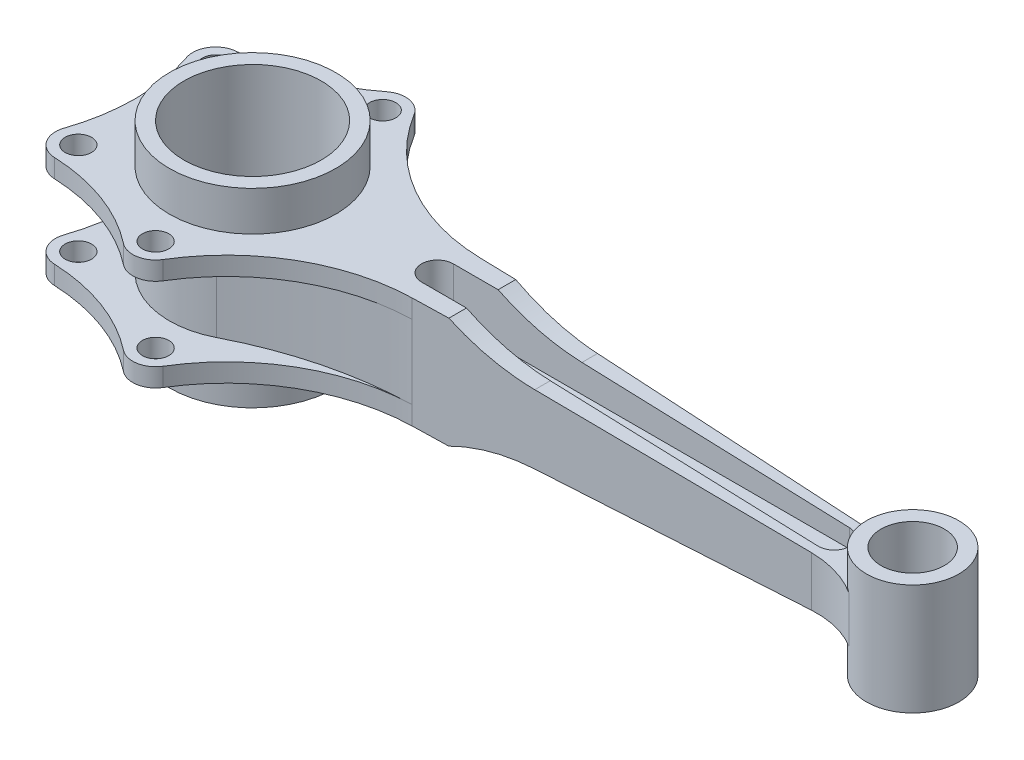
from build123d import *

# Parameters (mm, degrees)
SKETCH1_R                           = 31.5
SKETCH1_R_2                         = 26
BOSS_EXTRUDE4_DEPTH                 = 36
SKETCH1_6_R                         = 31.5
BOSS_EXTRUDE5_DEPTH                 = 21
SKETCH1_7_R                         = 17.499999999999996
SKETCH1_7_R_2                       = 12.000000000000032
BOSS_EXTRUDE6_DEPTH                 = 21
CUT_EXTRUDE2_DEPTH                  = 14
F_10_0_10_DIAMETER_HOLE1_AT_2_COUNT = 2
F_10_0_10_DIAMETER_HOLE1_AT_2_PITCH = 49.29432288112943
F_10_0_10_DIAMETER_HOLE1_AT_3_COUNT = 2
F_10_0_10_DIAMETER_HOLE1_AT_3_PITCH = 83.07785666655731
F_10_0_10_DIAMETER_HOLE1_AT_4_COUNT = 2
F_10_0_10_DIAMETER_HOLE1_AT_4_PITCH = 86
CUT_EXTRUDE3_DEPTH                  = 275.8107850129084
CUT_EXTRUDE5_START                  = 2.5
CUT_EXTRUDE5_DEPTH                  = 273.3107850129084
FILLET1_R                           = 35


with BuildPart() as part:
    # Sketch1 → Boss-Extrude4 (new, symmetric)
    with BuildSketch(Plane(origin=(0, 0, 0), x_dir=(1, 0, 0), z_dir=(0, 1, 0))):
        with Locations(Location((0, 0, 0), (0, 0, 270))):
            Circle(SKETCH1_R)
        with Locations(Location((0, 0, 0), (0, 0, 270))):
            Circle(SKETCH1_R_2, mode=Mode.SUBTRACT)
    extrude(amount=BOSS_EXTRUDE4_DEPTH, both=True)

    # Sketch1_6 → Boss-Extrude5 (add, symmetric)
    with BuildSketch(Plane(origin=(0, 0, 0), x_dir=(1, 0, 0), z_dir=(0, 1, 0))):
        with BuildLine():
            Line((73.36430221224288, -13), (234.99166898019635, -9))
            ThreePointArc((234.99166898019635, -8.999999999999988), (232.5, 2.14e-15), (234.99166898019635, 8.999999999999991))
            Line((234.99166898019635, 9), (73.36430221224288, 13))
            ThreePointArc((73.36430221224288, 13), (39.114969977483554, 22.641845358080204), (13.664667255675049, 47.506761038700624))
            ThreePointArc((13.664667255675045, 47.50676103870063), (7.823940970794196, 51.519100534686345), (0.9428180059327183, 49.82703123693257))
            ThreePointArc((0.9428180059327147, 49.827031236932584), (-18.520838663158816, 39.007076929693255), (-40.35979444370536, 34.65215413378165))
            ThreePointArc((-40.35979444370536, 34.65215413378164), (-47.144575584343094, 30.893287536620406), (-48.19740860349871, 23.20863556952498))
            ThreePointArc((-48.1974086034987, 23.208635569524983), (-44.3542808542188, 3.55e-15), (-48.19740860349869, -23.208635569524983))
            ThreePointArc((-48.19740860349871, -23.20863556952498), (-47.144575584343094, -30.893287536620406), (-40.35979444370536, -34.65215413378164))
            ThreePointArc((-40.35979444370536, -34.65215413378165), (-18.520838663158816, -39.007076929693255), (0.9428180059327147, -49.827031236932584))
            ThreePointArc((0.9428180059327183, -49.82703123693257), (7.823940970794196, -51.519100534686345), (13.664667255675045, -47.50676103870063))
            ThreePointArc((13.664667255675049, -47.506761038700624), (39.114969977483554, -22.641845358080204), (73.36430221224288, -13))
        make_face()
        with Locations(Location((0, 0, 0), (0, 0, 270))):
            Circle(SKETCH1_6_R, mode=Mode.SUBTRACT)
    extrude(amount=BOSS_EXTRUDE5_DEPTH, both=True)

    # Sketch3 → Cut-Extrude2 (cut, symmetric)
    with BuildSketch(Plane(origin=(0, 0, 0), x_dir=(1, 0, 0), z_dir=(0, 1, 0))):
        with BuildLine():
            ThreePointArc((13.664667255675027, -47.50676103870063), (39.11496997748354, -22.64184535808019), (73.36430221224288, -13))
            ThreePointArc((73.36430221224288, -13), (43.025431211720246, -17.18539121666319), (14.381730442456515, -28.025271265065697))
            ThreePointArc((14.38173044245655, -28.025271265065726), (-31.5, -1.013e-14), (14.381730442456531, 28.025271265065733))
            ThreePointArc((14.381730442456515, 28.025271265065697), (43.025431211720246, 17.18539121666319), (73.36430221224288, 13))
            ThreePointArc((73.36430221224288, 12.999999999999986), (39.11496997748353, 22.64184535808019), (13.664667255675035, 47.50676103870063))
            ThreePointArc((13.664667255675045, 47.50676103870064), (7.823940970794192, 51.519100534686345), (0.9428180059327165, 49.82703123693258))
            ThreePointArc((0.9428180059327147, 49.82703123693257), (-18.520838663158813, 39.00707692969324), (-40.35979444370537, 34.65215413378162))
            ThreePointArc((-40.35979444370537, 34.652154133781636), (-47.14457558434309, 30.89328753662039), (-48.197408603498715, 23.20863556952498))
            ThreePointArc((-48.19740860349873, 23.208635569524986), (-44.354280854218786, 5.33e-15), (-48.1974086034987, -23.20863556952498))
            ThreePointArc((-48.19740860349871, -23.20863556952498), (-47.14457558434308, -30.89328753662039), (-40.35979444370537, -34.652154133781636))
            ThreePointArc((-40.359794443705375, -34.65215413378162), (-18.520838663158816, -39.00707692969324), (0.9428180059327218, -49.82703123693256))
            ThreePointArc((0.9428180059327174, -49.82703123693258), (7.8239409707941885, -51.51910053468634), (13.664667255675035, -47.50676103870063))
        make_face()
    extrude(amount=CUT_EXTRUDE2_DEPTH, both=True, mode=Mode.SUBTRACT)

    # Sketch6 → Ø10.0 (10) Diameter Hole1 (revolve, cut)
    with BuildSketch(Plane(origin=(6.270187683961703, 21, -43), x_dir=(0, 0, 1), z_dir=(1, 0, 0))):
        Polygon((0, 0), (-1.396e-14, 56.99999999999999), (4.999999999999993, 56.99999999999999), (5, 5.5e-16), align=None)
    f_10_0_10_diameter_hole1 = revolve(axis=Axis((6.270187683961703, 27.34999999999999, -43), (0, -1, 0)), mode=Mode.SUBTRACT)

    # Ø10.0 (10) Diameter Hole1 at 2: Ø10.0 (10) Diameter Hole1 ×2
    with Locations(*[Vector(-0.9386514507063974, 0, 0.3448672992424417) * (i * F_10_0_10_DIAMETER_HOLE1_AT_2_PITCH) for i in range(1, F_10_0_10_DIAMETER_HOLE1_AT_2_COUNT)]):
        add(f_10_0_10_diameter_hole1, mode=Mode.SUBTRACT)

    # Ø10.0 (10) Diameter Hole1 at 3: Ø10.0 (10) Diameter Hole1 ×2
    with Locations(*[Vector(-0.5569497040549868, 0, 0.8305462221653065) * (i * F_10_0_10_DIAMETER_HOLE1_AT_3_PITCH) for i in range(1, F_10_0_10_DIAMETER_HOLE1_AT_3_COUNT)]):
        add(f_10_0_10_diameter_hole1, mode=Mode.SUBTRACT)

    # Ø10.0 (10) Diameter Hole1 at 4: Ø10.0 (10) Diameter Hole1 ×2
    with Locations(*[(0, 0, i * F_10_0_10_DIAMETER_HOLE1_AT_4_PITCH) for i in range(1, F_10_0_10_DIAMETER_HOLE1_AT_4_COUNT)]):
        add(f_10_0_10_diameter_hole1, mode=Mode.SUBTRACT)

    # Sketch7 → Cut-Extrude3 (cut, symmetric)
    with BuildSketch(Plane.XY):
        with BuildLine():
            Line((233.74583449009816, 9.00000000000001), (118.75183062971695, 13.015679101740716))
            ThreePointArc((118.75183062971695, 13.015679101740716), (102.45227278301908, 15.323109429183773), (87, 21))
            Line((87, 21), (233.74583449009816, 21))
            Line((233.74583449009816, 21), (250, 21))
            Line((250, 21), (250, 8.432392032948131))
            Line((250, 8.432392032948131), (233.74583449009816, 9.00000000000001))
        make_face()
    cut_extrude3 = extrude(amount=CUT_EXTRUDE3_DEPTH, both=True, mode=Mode.SUBTRACT)

    # Mirror1: Cut-Extrude3 across plane
    add(cut_extrude3.mirror(Plane.ZX), mode=Mode.SUBTRACT)

    # Sketch8 → Cut-Extrude5 (cut, through all)
    with BuildSketch(Plane(origin=(0, 0, 0), x_dir=(1, 0, 0), z_dir=(0, 1, 0)).offset(CUT_EXTRUDE5_START)):
        with BuildLine():
            Line((70, 6), (220, 6))
            ThreePointArc((220, 6), (226, 0), (220, -6))
            Line((220, -6), (70, -6))
            ThreePointArc((70, -6), (64.00000000000003, 7.3e-16), (70, 6))
        make_face()
    cut_extrude5 = extrude(amount=CUT_EXTRUDE5_DEPTH, mode=Mode.SUBTRACT)

    # Mirror2: Cut-Extrude5 across plane
    add(cut_extrude5.mirror(Plane.ZX), mode=Mode.SUBTRACT)


with BuildPart() as body_2:
    # Sketch1_7 → Boss-Extrude6 (new, symmetric)
    with BuildSketch(Plane(origin=(0, 0, 0), x_dir=(1, 0, 0), z_dir=(0, 1, 0))):
        with Locations(Location((250, 0, 0), (0, 0, 90))):
            Circle(SKETCH1_7_R)
        with Locations(Location((250, 0, 0), (0, 0, 90))):
            Circle(SKETCH1_7_R_2, mode=Mode.SUBTRACT)
    extrude(amount=BOSS_EXTRUDE6_DEPTH, both=True)


with BuildPart() as part_1:
    add(part.part)

    # Combine1: union body 2
    add(body_2.part)

    # Fillet1
    fillet1_edges = [part_1.edges().sort_by_distance(p)[0] for p in [
        (234.99166898019635, 0, -8.999999999999996),
        (234.99166898019635, 0, 8.999999999999995),
    ]]
    fillet(fillet1_edges, radius=FILLET1_R)


solid = part_1.part
